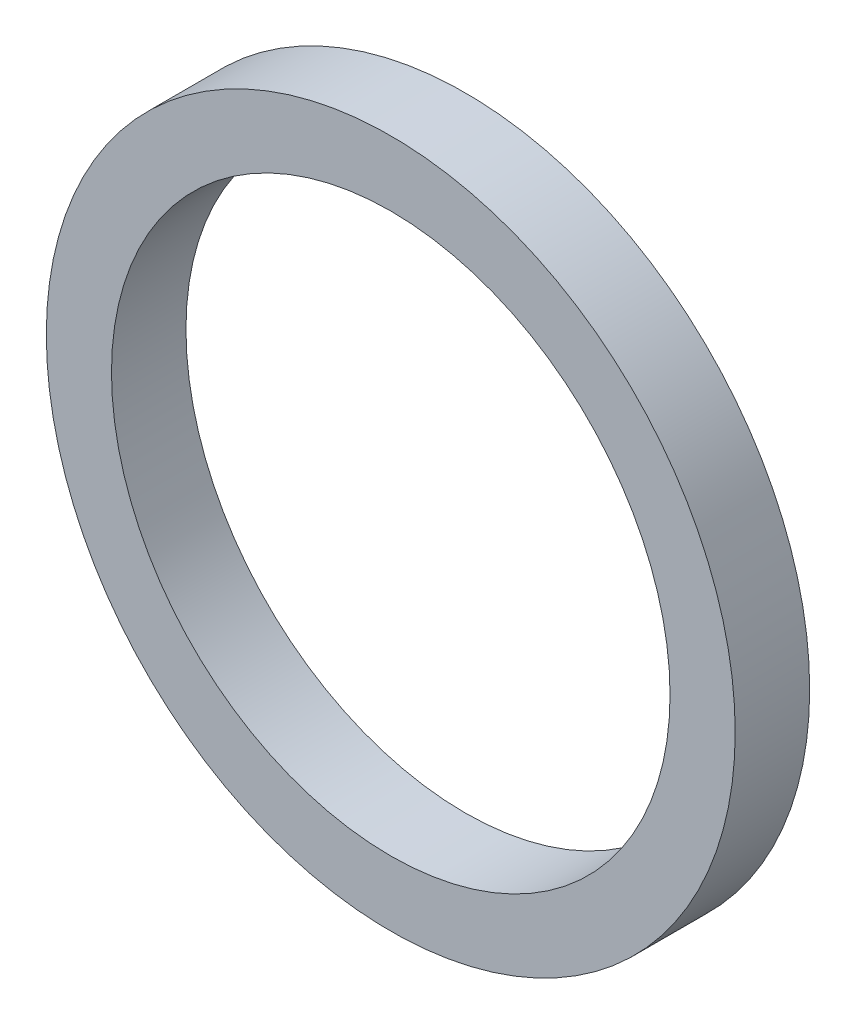
from build123d import *

# Parameters (mm, degrees)
SKETCH_1_R      = 18.5
SKETCH_1_R_2    = 15
EXTRUDE_1_DEPTH = 4


with BuildPart() as part:
    # 草图1 → 凸台-拉伸1 (new body)
    with BuildSketch(Plane.XY):
        Circle(SKETCH_1_R)
        Circle(SKETCH_1_R_2, mode=Mode.SUBTRACT)
    extrude(amount=EXTRUDE_1_DEPTH)


solid = part.part
